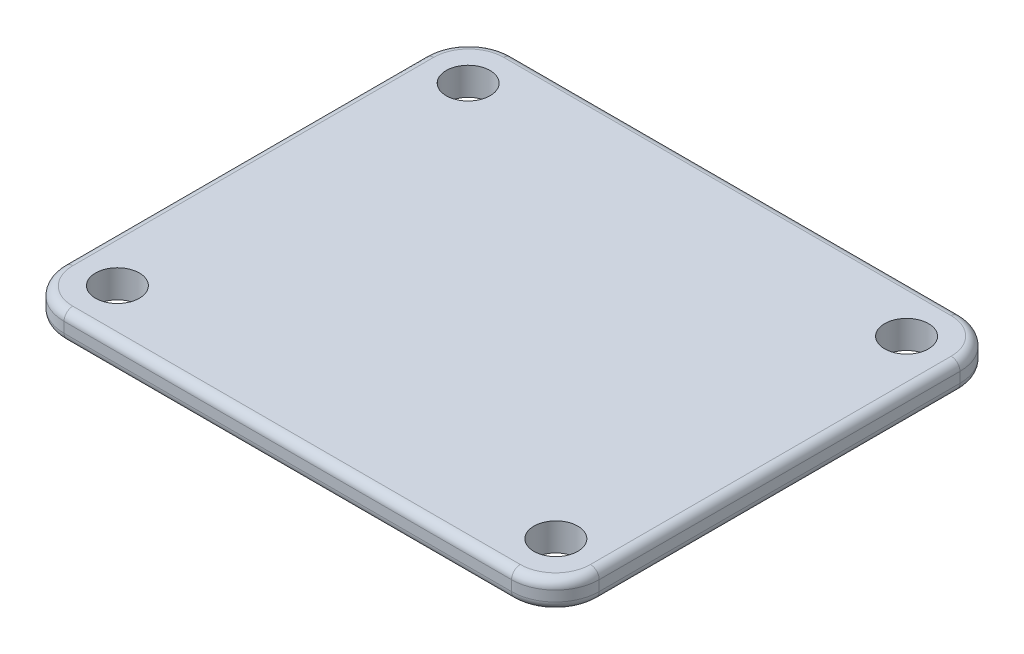
from build123d import *

# Parameters (mm, degrees)
SKETCH1_R           = 2.499798637
BOSS_EXTRUDE1_DEPTH = 3.175
FILLET1_R           = 1


with BuildPart() as part:
    # Sketch1 → Boss-Extrude1 (new body)
    with BuildSketch(Plane(origin=(0, 0, 0), x_dir=(1, 0, 0), z_dir=(0, 1, 0))):
        with BuildLine():
            Line((-67.701379439, -26.588630041), (-118.732469461, -26.59066957))
            ThreePointArc((-118.732469461, -26.59066957), (-122.268132547, -25.126274131), (-123.732669293, -21.590669574))
            Line((-123.732669293, -21.590669574), (-123.732669293, 19.553345865))
            ThreePointArc((-123.732669293, 19.553345865), (-122.268209036, 23.088873934), (-118.732685802, 24.553345865))
            Line((-118.732685802, 24.553345865), (-67.702190036, 24.553514364))
            ThreePointArc((-67.702190036, 24.553514364), (-64.166670991, 23.08907964), (-62.702173527, 19.553586583))
            Line((-62.702173527, 19.553586583), (-62.701579271, -21.588557825))
            ThreePointArc((-62.701579271, -21.588557825), (-64.165949181, -25.124067765), (-67.701379439, -26.588630041))
        make_face()
        with Locations((-118.217169293, 18.981347567)):
            Circle(SKETCH1_R, mode=Mode.SUBTRACT)
        with Locations((-68.217665265, 18.981512662)):
            Circle(SKETCH1_R, mode=Mode.SUBTRACT)
        with Locations((-68.217087532, -21.016650648)):
            Circle(SKETCH1_R, mode=Mode.SUBTRACT)
        with Locations((-118.217169293, -21.018648971)):
            Circle(SKETCH1_R, mode=Mode.SUBTRACT)
    extrude(amount=BOSS_EXTRUDE1_DEPTH)

    # Fillet1
    fillet1_edges = [part.edges().sort_by_distance(p)[0] for p in [
        (-122.268132547, 3.175, 25.126274131),
        (-123.732669293, 0, 1.018661855),
        (-122.268209036, 0, -23.088873934),
        (-93.21692445, 3.175, 26.589649806),
        (-64.165949181, 3.175, 25.124067765),
        (-62.701876399, 3.175, 1.017485621),
        (-64.166670991, 3.175, -23.08907964),
        (-93.217437919, 3.175, -24.553430114),
        (-122.268209036, 3.175, -23.088873934),
        (-123.732669293, 3.175, 1.018661855),
        (-93.217437919, 0, -24.553430114),
        (-64.166670991, 0, -23.08907964),
        (-62.701876399, 0, 1.017485621),
        (-64.165949181, 0, 25.124067765),
        (-93.21692445, 0, 26.589649806),
        (-122.268132547, 0, 25.126274131),
    ]]
    fillet(fillet1_edges, radius=FILLET1_R)


solid = part.part
